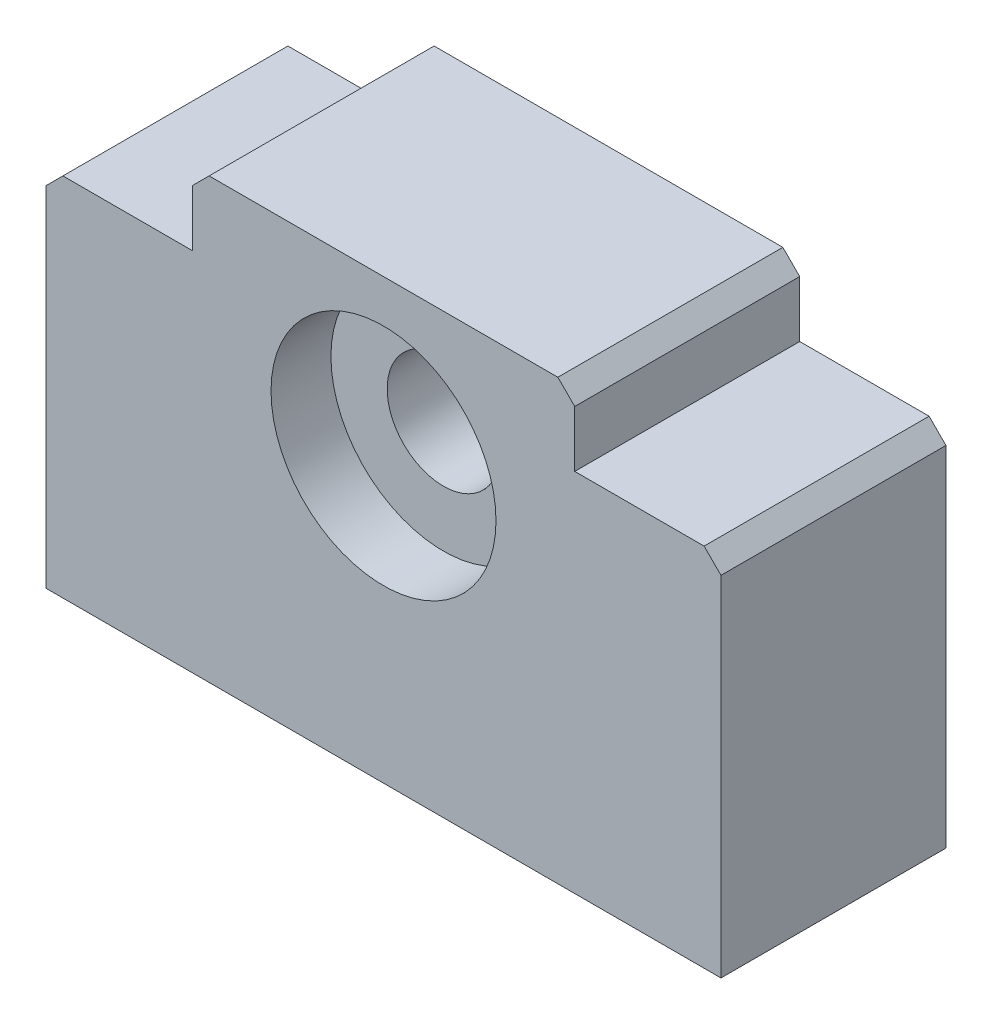
from build123d import *

# Parameters (mm, degrees)
SALIENTE_EXTRUIR1_DEPTH = 20
CROQUIS2_R              = 5
CORTAR_EXTRUIR1_DEPTH   = 21
CHAFL_N1_SIZE           = 1.5
CROQUIS3_R              = 10
CORTAR_EXTRUIR2_DEPTH   = 5.325
CROQUIS5_R              = 10
CORTAR_EXTRUIR3_DEPTH   = 5.325


with BuildPart() as part:
    # Croquis1 → Saliente-Extruir1 (new body)
    with BuildSketch(Plane.XY):
        Polygon((-30, 16.25), (-17, 16.25), (-17, 22.75), (17, 22.75), (17, 16.25), (30, 16.25), (30, -16.25), (-30, -16.25), align=None)
    extrude(amount=SALIENTE_EXTRUIR1_DEPTH)

    # Croquis2 → Cortar-Extruir1 (cut, through all)
    with BuildSketch(Plane.XY):
        with Locations((0, 8.95)):
            Circle(CROQUIS2_R)
    extrude(amount=CORTAR_EXTRUIR1_DEPTH, mode=Mode.SUBTRACT)

    # Chaflán1
    chafl_n1_edges = [part.edges().sort_by_distance(p)[0] for p in [
        (-30, 16.25, 10),
        (-17, 22.75, 10),
        (17, 22.75, 10),
        (30, 16.25, 10),
    ]]
    chamfer(chafl_n1_edges, length=CHAFL_N1_SIZE)

    # Croquis3 → Cortar-Extruir2 (cut)
    with BuildSketch(Plane.XY):
        with Locations((0, 8.851953405)):
            Circle(CROQUIS3_R)
    extrude(amount=CORTAR_EXTRUIR2_DEPTH, mode=Mode.SUBTRACT)

    # Croquis5 → Cortar-Extruir3 (cut)
    with BuildSketch(Plane.XY.offset(20)):
        with Locations((0, 8.95)):
            Circle(CROQUIS5_R)
    extrude(amount=-CORTAR_EXTRUIR3_DEPTH, mode=Mode.SUBTRACT)


solid = part.part
